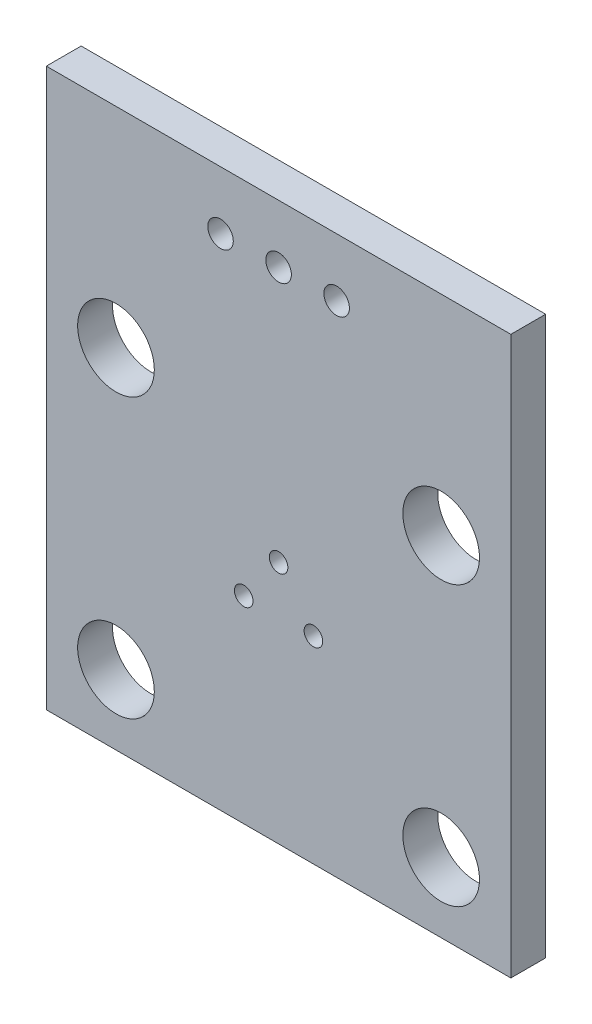
from build123d import *

# Parameters (mm, degrees)
SKETCH_1_W      = 20
SKETCH_1_H      = 24
SKETCH_1_R      = 1.65
SKETCH_1_R_2    = 0.55
SKETCH_1_R_3    = 0.4
EXTRUDE_1_DEPTH = 1.5


with BuildPart() as part:
    # Эскиз1 → Бобышка-Вытянуть1 (new body)
    with BuildSketch(Plane.XY):
        with Locations((10, 12)):
            Rectangle(SKETCH_1_W, SKETCH_1_H)
        with Locations((3, 3)):
            Circle(SKETCH_1_R, mode=Mode.SUBTRACT)
        with Locations((17, 3)):
            Circle(SKETCH_1_R, mode=Mode.SUBTRACT)
        with Locations((17, 15)):
            Circle(SKETCH_1_R, mode=Mode.SUBTRACT)
        with Locations((3, 15)):
            Circle(SKETCH_1_R, mode=Mode.SUBTRACT)
        with Locations((7.5, 21.5)):
            Circle(SKETCH_1_R_2, mode=Mode.SUBTRACT)
        with Locations((10, 21.5)):
            Circle(SKETCH_1_R_2, mode=Mode.SUBTRACT)
        with Locations((12.5, 21.5)):
            Circle(SKETCH_1_R_2, mode=Mode.SUBTRACT)
        with Locations((10, 10.5)):
            Circle(SKETCH_1_R_3, mode=Mode.SUBTRACT)
        with Locations((11.5, 8.5)):
            Circle(SKETCH_1_R_3, mode=Mode.SUBTRACT)
        with Locations((8.5, 8.5)):
            Circle(SKETCH_1_R_3, mode=Mode.SUBTRACT)
    extrude(amount=EXTRUDE_1_DEPTH)


solid = part.part
